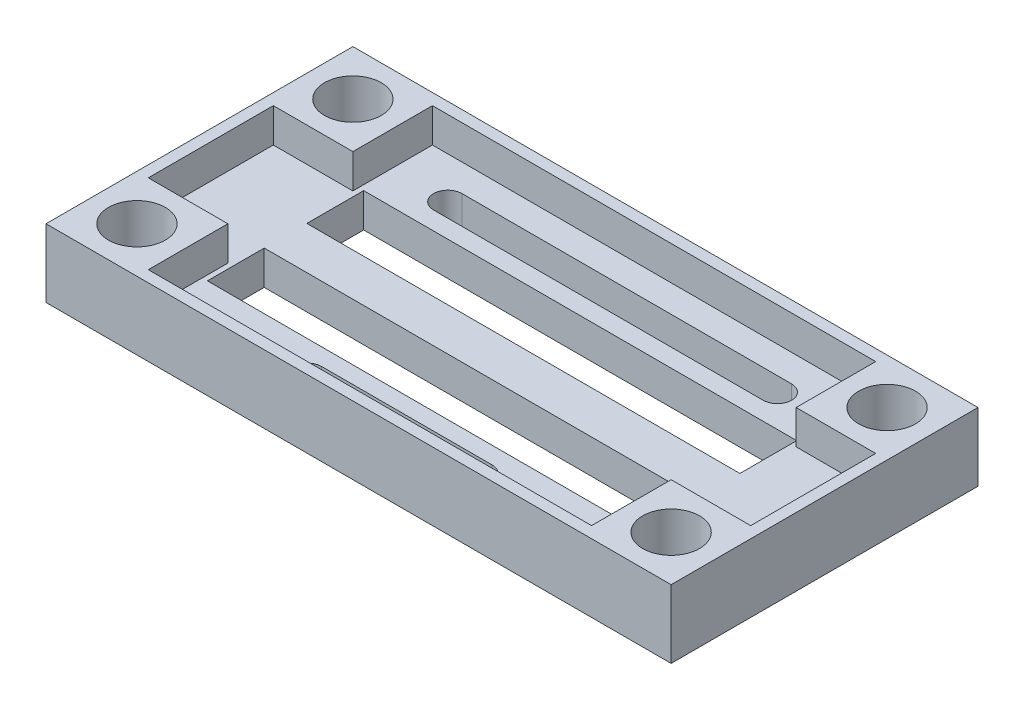
from build123d import *

# Parameters (mm, degrees)
SKETCH1_W                   = 55
SKETCH1_H                   = 27
SKETCH1_W_2                 = 38.1
SKETCH1_H_2                 = 5
BOTTOM_BASE_DEPTH           = 3
SENSOR_MOUNTING_HOLES_DEPTH = 3
SKETCH4_W                   = 55
SKETCH4_H                   = 27
SKETCH4_W_2                 = 53
SKETCH4_H_2                 = 25
SKETCH4_W_3                 = 7
SKETCH4_H_3                 = 7
OUTER_RIM_DEPTH             = 3
M4_BOLT_HOLES_D             = 5
BACKWARDS_SENSOR_DEPTH      = 3


with BuildPart() as part:
    # Sketch1 → Bottom Base (new body)
    with BuildSketch(Plane(origin=(0, 0, 0), x_dir=(1, 0, 0), z_dir=(0, 1, 0))):
        Rectangle(SKETCH1_W, SKETCH1_H)
        with Locations((0, -5.25)):
            Rectangle(SKETCH1_W_2, SKETCH1_H_2, mode=Mode.SUBTRACT)
        with Locations((0, 3.5)):
            Rectangle(SKETCH1_W_2, SKETCH1_H_2, mode=Mode.SUBTRACT)
    extrude(amount=BOTTOM_BASE_DEPTH)

    # Sketch3 → Sensor Mounting Holes (cut)
    with BuildSketch(Plane(origin=(0, 3, 0), x_dir=(1, 0, 0), z_dir=(0, 1, 0))):
        with BuildLine():
            Line((-14.5, 10.1), (14.500000132, 10.1))
            ThreePointArc((14.500000132, 10.1), (15.750000132, 8.85), (14.500000132, 7.6))
            Line((14.500000132, 7.6), (-14.5, 7.6))
            ThreePointArc((-14.5, 7.6), (-15.75, 8.85), (-14.5, 10.1))
        make_face()
    extrude(amount=-SENSOR_MOUNTING_HOLES_DEPTH, mode=Mode.SUBTRACT)

    # Sketch4 → Outer Rim (add)
    with BuildSketch(Plane(origin=(0, 3, 0), x_dir=(1, 0, 0), z_dir=(0, 1, 0))):
        Rectangle(SKETCH4_W, SKETCH4_H)
        Rectangle(SKETCH4_W_2, SKETCH4_H_2, mode=Mode.SUBTRACT)
        with Locations((23, 9)):
            Rectangle(SKETCH4_W_3, SKETCH4_H_3)
        with Locations((23, -9)):
            Rectangle(SKETCH4_W_3, SKETCH4_H_3)
        with Locations((-23, -9)):
            Rectangle(SKETCH4_W_3, SKETCH4_H_3)
        with Locations((-23, 9)):
            Rectangle(SKETCH4_W_3, SKETCH4_H_3)
    extrude(amount=OUTER_RIM_DEPTH)

    # M4 bolt holes (through all)
    with Locations(Plane(origin=(0, 6, 0), x_dir=(1, 0, 0), z_dir=(0, 1, 0))):
        with Locations((-23.5, 9.5), (-23.5, -9.5), (23.5, 9.5), (23.5, -9.5)):
            Hole(M4_BOLT_HOLES_D / 2)

    # Sketch11 → backwards sensor (cut)
    with BuildSketch(Plane(origin=(0, 3, 0), x_dir=(1, 0, 0), z_dir=(0, 1, 0))):
        with BuildLine():
            Line((-7.5, -9.25), (7.5, -9.25))
            ThreePointArc((7.5, -9.25), (8.75, -10.5), (7.5, -11.75))
            Line((7.5, -11.75), (-7.5, -11.75))
            ThreePointArc((-7.5, -11.75), (-8.75, -10.5), (-7.5, -9.25))
        make_face()
    extrude(amount=-BACKWARDS_SENSOR_DEPTH, mode=Mode.SUBTRACT)


solid = part.part
